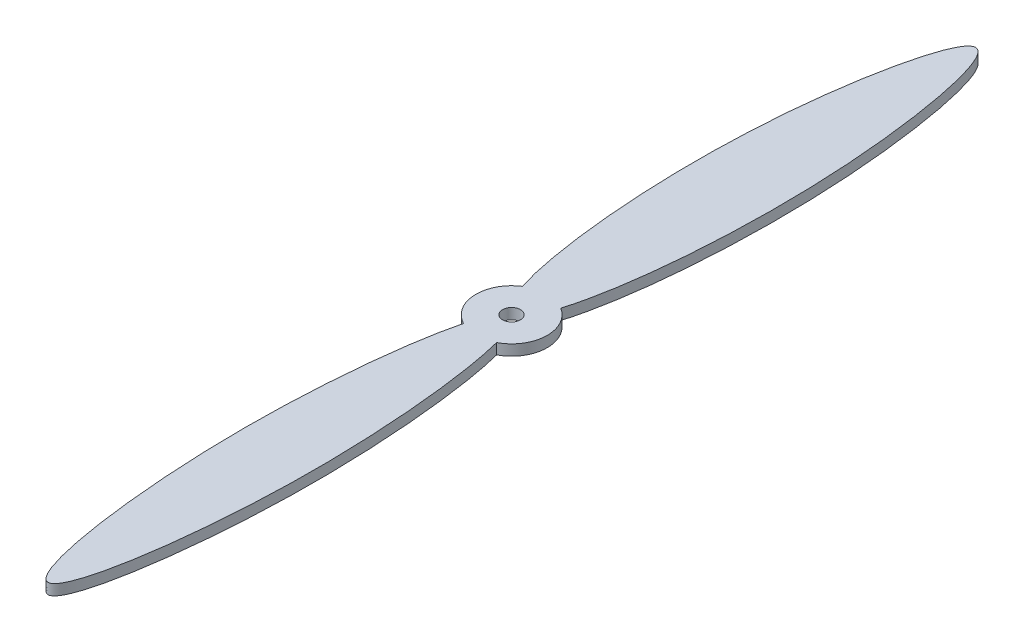
from build123d import *

# Parameters (mm, degrees)
SKETCH1_R           = 3.175
BOSS_EXTRUDE1_DEPTH = 3.81


with BuildPart() as part:
    # Sketch1 → Boss-Extrude1 (new body)
    with BuildSketch(Plane(origin=(0, 0, 0), x_dir=(1, 0, 0), z_dir=(0, 1, 0))):
        with BuildLine():
            add(Edge.make_bspline(
                [(-6.891438373, 10.667618157), (-13.141739885, 30.574831134), (-19.587668331, 99.881131685), (0.626884387, 189.415109593), (18.684158102, 98.500490429), (12.553876864, 30.066409487), (6.706113203, 10.785084409)],
                knots=[0.090442646, 0.090442646, 0.090442646, 0.090442646, 0.354535083, 0.500151659, 0.657030324, 0.910712035, 0.910712035, 0.910712035, 0.910712035], degree=3))
            ThreePointArc((6.706113203, 10.785084409), (12.691411814, -0.466975555), (5.895386784, -11.248751694))
            add(Edge.make_bspline(
                [(-5.88391039, -11.254758928), (-9.866416239, -26.666488161), (-16.994481981, -95.929253478), (-0.026632418, -205.140276042), (16.989967462, -96.014162194), (9.887816855, -26.705317248), (5.895386784, -11.248751694)],
                knots=[0.080128559, 0.080128559, 0.080128559, 0.080128559, 0.256247262, 0.4994985, 0.741948497, 0.918677056, 0.918677056, 0.918677056, 0.918677056], degree=3))
            ThreePointArc((-5.88391039, -11.254758928), (-12.68660862, -0.583062373), (-6.891438373, 10.667618157))
        make_face()
        with Locations((-0.037840034, -0.000665164)):
            Circle(SKETCH1_R, mode=Mode.SUBTRACT)
    extrude(amount=BOSS_EXTRUDE1_DEPTH)


solid = part.part
